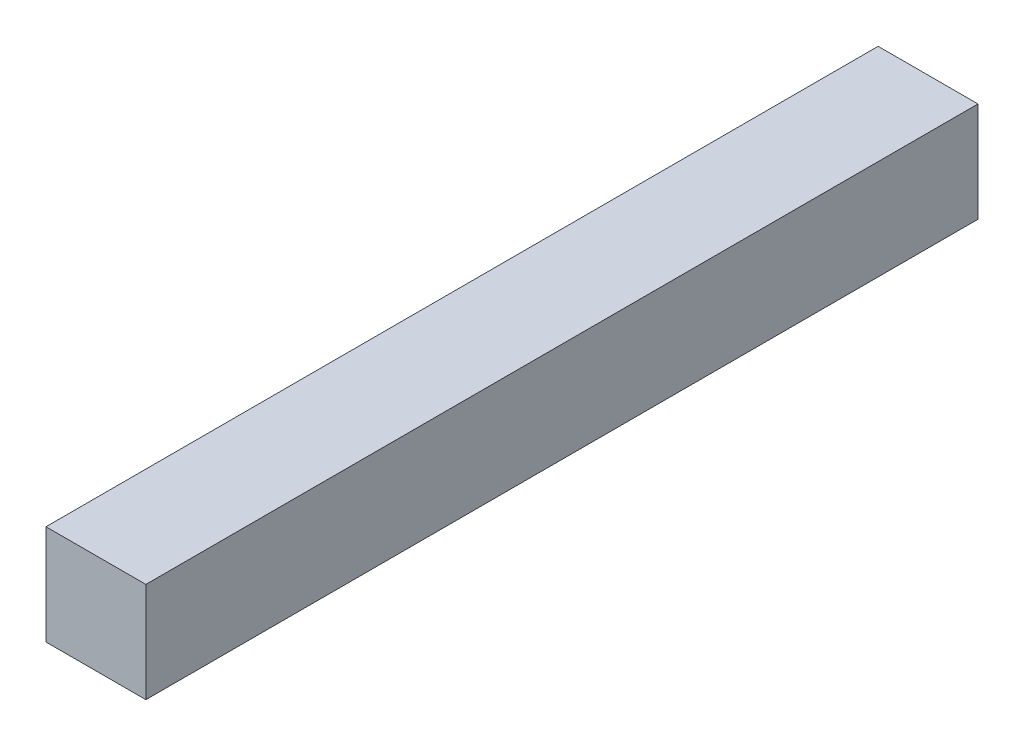
from build123d import *

# Parameters (mm, degrees)
SKETCH1_W           = 6
SKETCH1_H           = 6
BOSS_EXTRUDE1_DEPTH = 50


with BuildPart() as part:
    # Sketch1 → Boss-Extrude1 (new body)
    with BuildSketch(Plane.XY):
        Rectangle(SKETCH1_W, SKETCH1_H)
    extrude(amount=BOSS_EXTRUDE1_DEPTH)


solid = part.part
